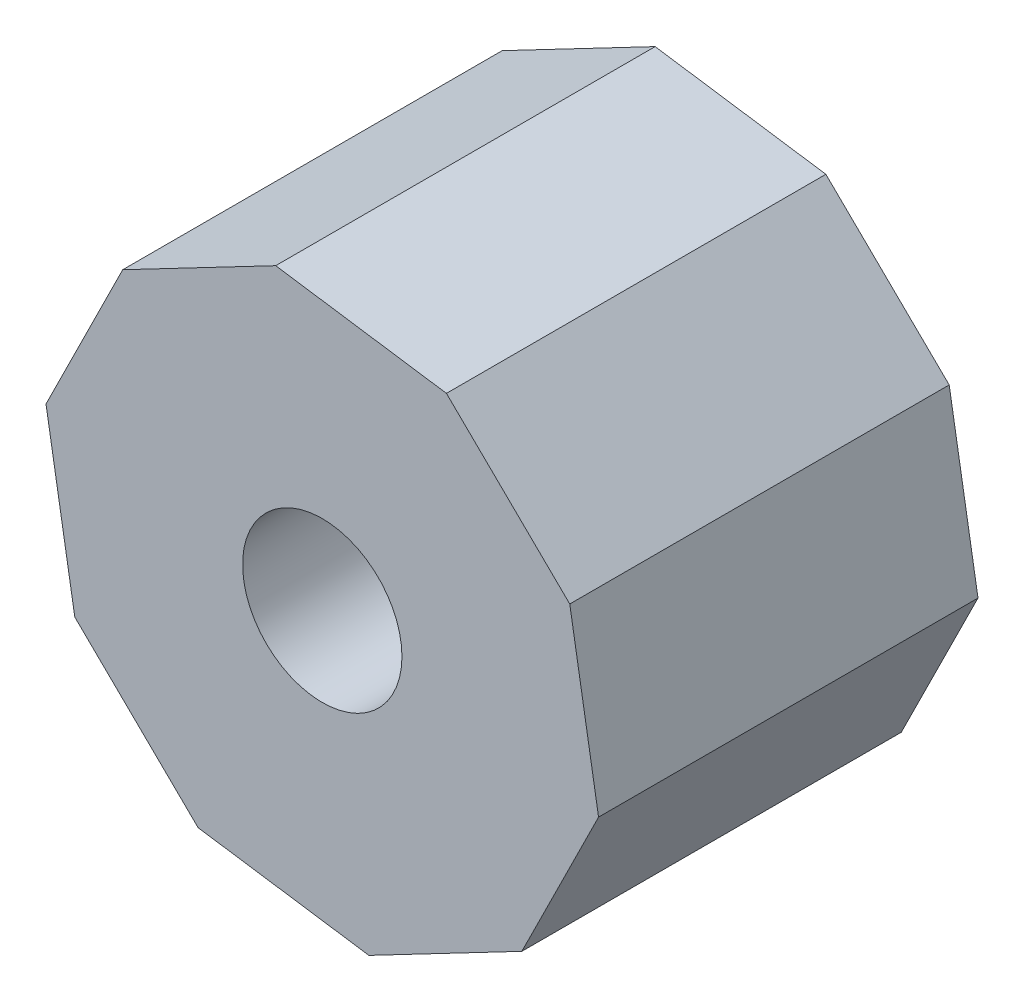
from build123d import *

# Parameters (mm, degrees)
BOSS_EXTRU_1_DEPTH = 10
ESQUISSE3_R        = 4.517940726
ESQUISSE3_R_2      = 2.1
BOSS_EXTRU_2_DEPTH = 4


with BuildPart() as part:
    # Esquisse1 → Boss.-Extru.1 (new body)
    with BuildSketch(Plane.XY):
        Polygon((-5.259154953, 5.14920934), (-7.281375044, 1.074544143), (-6.522357353, -3.410560394), (-3.27202084, -6.592946782), (1.228116422, -7.257051584), (5.259154953, -5.14920934), (7.281375044, -1.074544143), (6.522357353, 3.410560394), (3.27202084, 6.592946782), (-1.228116422, 7.257051584), align=None)
        Polygon((1.509357523, -3.811190523), (4.055266573, -0.598453303), (2.54590905, 3.21273722), (-1.509357523, 3.811190523), (-4.055266573, 0.598453303), (-2.54590905, -3.21273722), align=None, mode=Mode.SUBTRACT)
    extrude(amount=BOSS_EXTRU_1_DEPTH)

    # Esquisse3 → Boss.-Extru.2 (add)
    with BuildSketch(Plane.XY.offset(10)):
        Circle(ESQUISSE3_R)
        Circle(ESQUISSE3_R_2, mode=Mode.SUBTRACT)
    extrude(amount=-BOSS_EXTRU_2_DEPTH)


solid = part.part
